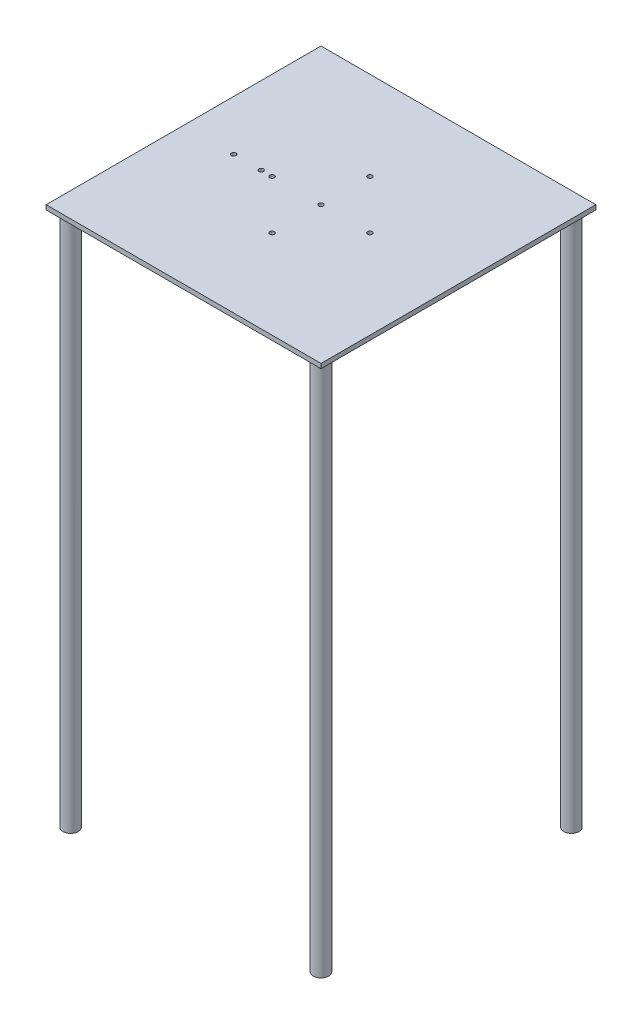
from build123d import *

# Parameters (mm, degrees)
SKETCH1_W           = 180
SKETCH1_H           = 180
SKETCH1_R           = 1.5
BOSS_EXTRUDE1_DEPTH = 3
SKETCH2_R           = 1.5
CUT_EXTRUDE1_DEPTH  = 4
SKETCH3_R           = 5
BOSS_EXTRUDE2_DEPTH = 350


with BuildPart() as part:
    # Sketch1 → Boss-Extrude1 (new body)
    with BuildSketch(Plane(origin=(0, 0, 0), x_dir=(1, 0, 0), z_dir=(0, 1, 0))):
        with Locations((-90, 90)):
            Rectangle(SKETCH1_W, SKETCH1_H)
        with Locations((-90, 90)):
            Circle(SKETCH1_R, mode=Mode.SUBTRACT)
        with Locations((-58, 90)):
            Circle(SKETCH1_R, mode=Mode.SUBTRACT)
        with Locations((-122, 90)):
            Circle(SKETCH1_R, mode=Mode.SUBTRACT)
        with Locations((-90, 122)):
            Circle(SKETCH1_R, mode=Mode.SUBTRACT)
        with Locations((-90, 58)):
            Circle(SKETCH1_R, mode=Mode.SUBTRACT)
    extrude(amount=BOSS_EXTRUDE1_DEPTH)

    # Sketch2 → Cut-Extrude1 (cut, through all)
    with BuildSketch(Plane(origin=(0, 3, 0), x_dir=(1, 0, 0), z_dir=(0, 1, 0))):
        with Locations((-147.18268, 90)):
            Circle(SKETCH2_R)
        with Locations((-129.18268, 90)):
            Circle(SKETCH2_R)
    extrude(amount=-CUT_EXTRUDE1_DEPTH, mode=Mode.SUBTRACT)

    # Sketch3 → Boss-Extrude2 (add)
    with BuildSketch(Plane.XZ):
        with Locations((-172, -8)):
            Circle(SKETCH3_R)
        with Locations((-8, -8)):
            Circle(SKETCH3_R)
        with Locations((-8, -172)):
            Circle(SKETCH3_R)
        with Locations((-172, -172)):
            Circle(SKETCH3_R)
    extrude(amount=BOSS_EXTRUDE2_DEPTH)


solid = part.part
